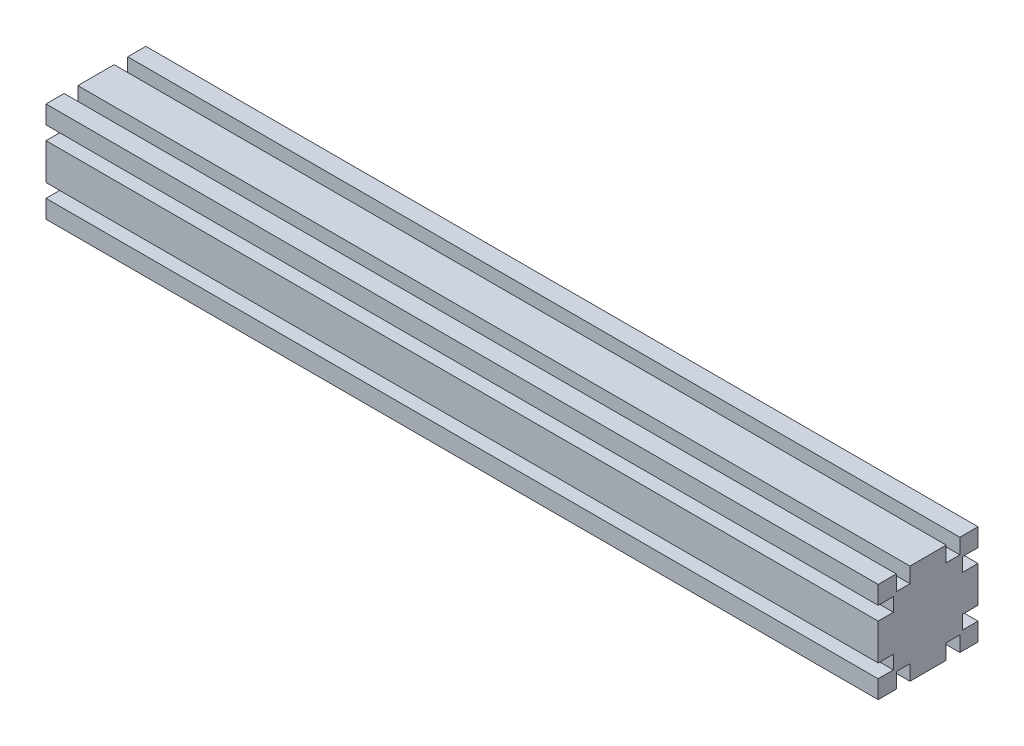
from build123d import *

# Parameters (mm, degrees)
SKETCH_1_W          = 60
SKETCH_1_H          = 60
EXTRUDE_1_DEPTH     = 500
SKETCH_2_W          = 8.2
SKETCH_2_H          = 9.2
SKETCH_2_W_2        = 9.2
SKETCH_2_H_2        = 8.2
CUT_EXTRUDE_1_DEPTH = 501


with BuildPart() as part:
    # 草图1 → 凸台-拉伸1 (new body)
    with BuildSketch(Plane(origin=(0, 0, 0), x_dir=(0, 0, -1), z_dir=(1, 0, 0))):
        Rectangle(SKETCH_1_W, SKETCH_1_H)
    extrude(amount=EXTRUDE_1_DEPTH)

    # 草图2 → 切除-拉伸1 (cut, through all)
    with BuildSketch(Plane.ZY):
        with Locations((-15, 25.4)):
            Rectangle(SKETCH_2_W, SKETCH_2_H)
        with Locations((-15, -25.4)):
            Rectangle(SKETCH_2_W, SKETCH_2_H)
        with Locations((15, -25.4)):
            Rectangle(SKETCH_2_W, SKETCH_2_H)
        with Locations((15, 25.4)):
            Rectangle(SKETCH_2_W, SKETCH_2_H)
        with Locations((-25.4, 15)):
            Rectangle(SKETCH_2_W_2, SKETCH_2_H_2)
        with Locations((-25.4, -15)):
            Rectangle(SKETCH_2_W_2, SKETCH_2_H_2)
        with Locations((25.4, -15)):
            Rectangle(SKETCH_2_W_2, SKETCH_2_H_2)
        with Locations((25.4, 15)):
            Rectangle(SKETCH_2_W_2, SKETCH_2_H_2)
    extrude(amount=-CUT_EXTRUDE_1_DEPTH, mode=Mode.SUBTRACT)


solid = part.part
